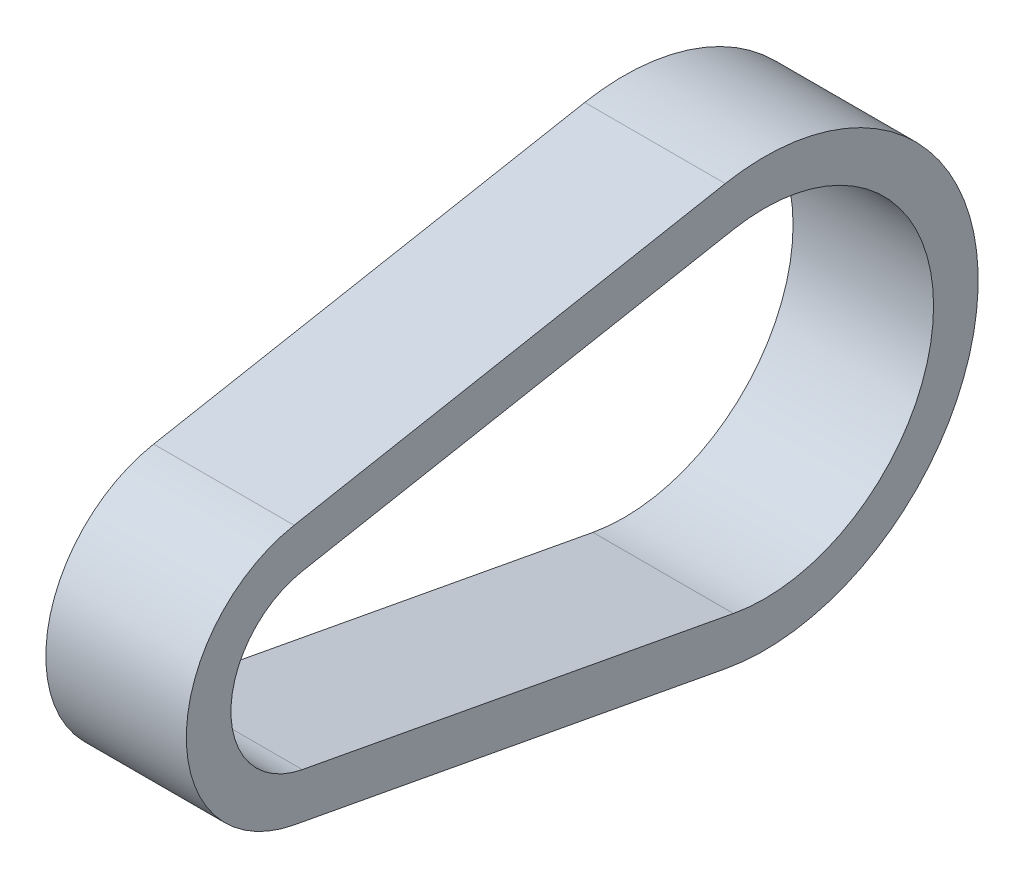
from build123d import *

# Parameters (mm, degrees)
BOSS_EXTRUDE1_DEPTH = 7.5


with BuildPart() as part:
    # Sketch1 → Boss-Extrude1 (new body, symmetric)
    with BuildSketch(Plane(origin=(0, 0, 0), x_dir=(0, 0, -1), z_dir=(1, 0, 0))):
        with BuildLine():
            Line((-2.582856777, 13.855780511), (43.442810752, 22.435427625))
            ThreePointArc((43.442810752, 22.435427625), (70.4469, 0), (43.442810752, -22.435427625))
            Line((43.442810752, -22.435427625), (-2.582856777, -13.855780511))
            ThreePointArc((-2.582856777, -13.855780511), (-14.09446, 0), (-2.582856777, 13.855780511))
        make_face()
        with BuildLine():
            Line((-1.710112777, 9.173930005), (44.315554752, 17.753577119))
            ThreePointArc((44.315554752, 17.753577119), (65.6844, 0), (44.315554752, -17.753577119))
            Line((44.315554752, -17.753577119), (-1.710112777, -9.173930005))
            ThreePointArc((-1.710112777, -9.173930005), (-9.33196, 0), (-1.710112777, 9.173930005))
        make_face(mode=Mode.SUBTRACT)
    extrude(amount=BOSS_EXTRUDE1_DEPTH, both=True)


solid = part.part
